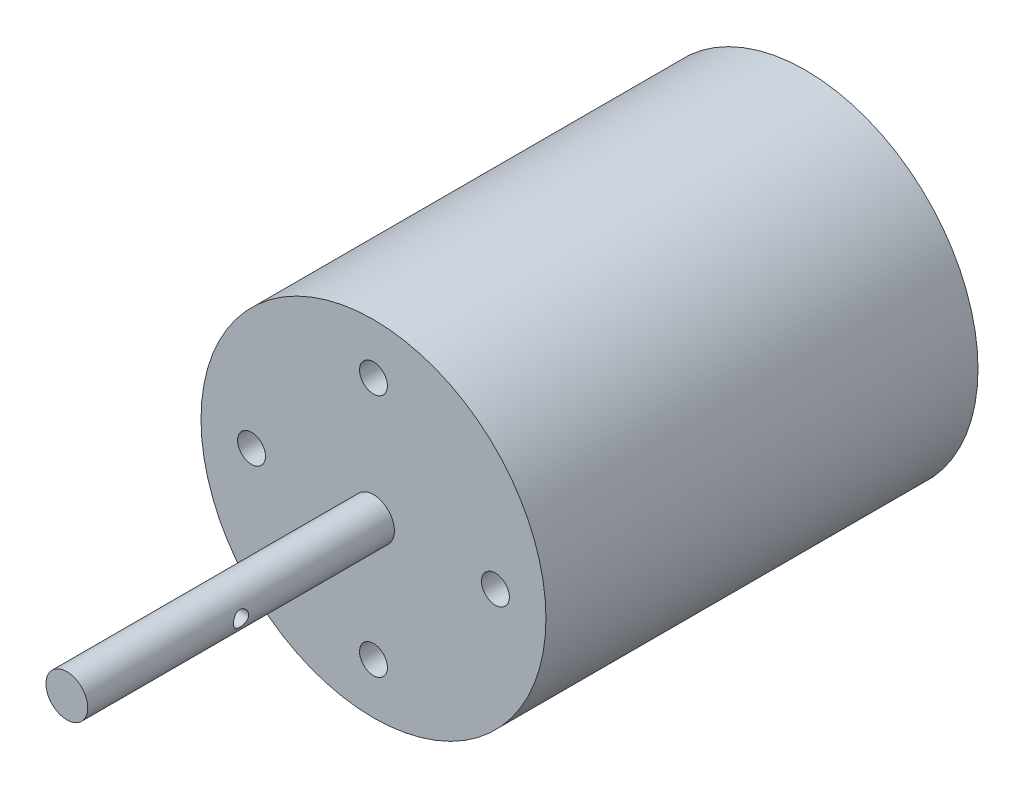
from build123d import *

# Parameters (mm, degrees)
SKETCH1_R               = 24.75
BOSS_EXTRUDE1_DEPTH     = 62
SKETCH2_R               = 3
BOSS_EXTRUDE2_DEPTH     = 44
SKETCH3_R               = 1.1
CUT_EXTRUDE1_DEPTH      = 25.75
CUT_EXTRUDE1_DEPTH_BACK = 25.75
SKETCH4_R               = 9
BOSS_EXTRUDE3_DEPTH     = 7
SKETCH5_R               = 2
CUT_EXTRUDE2_DEPTH      = 10
SKETCH6_R               = 2
CUT_EXTRUDE3_DEPTH      = 5


with BuildPart() as part:
    # Sketch1 → Boss-Extrude1 (new body)
    with BuildSketch(Plane.XY):
        Circle(SKETCH1_R)
    extrude(amount=-BOSS_EXTRUDE1_DEPTH)

    # Sketch2 → Boss-Extrude2 (add)
    with BuildSketch(Plane.XY):
        Circle(SKETCH2_R)
    extrude(amount=BOSS_EXTRUDE2_DEPTH)

    # Sketch3 → Cut-Extrude1 (cut, two sides)
    with BuildSketch(Plane(origin=(0, 0, 0), x_dir=(0, 0, -1), z_dir=(1, 0, 0))) as cut_extrude1_sk:
        with Locations((-22, 0)):
            Circle(SKETCH3_R)
    extrude(amount=CUT_EXTRUDE1_DEPTH, mode=Mode.SUBTRACT)
    extrude(cut_extrude1_sk.sketch, amount=-CUT_EXTRUDE1_DEPTH_BACK, mode=Mode.SUBTRACT)

    # Sketch4 → Boss-Extrude3 (add)
    with BuildSketch(Plane(origin=(0, 0, -62), x_dir=(-1, 0, 0), z_dir=(0, 0, -1))):
        Circle(SKETCH4_R)
    extrude(amount=BOSS_EXTRUDE3_DEPTH)

    # Sketch5 → Cut-Extrude2 (cut)
    with BuildSketch(Plane(origin=(0, 0, -62), x_dir=(-1, 0, 0), z_dir=(0, 0, -1))):
        with Locations((-17.5, 0)):
            Circle(SKETCH5_R)
        with Locations((17.5, 0)):
            Circle(SKETCH5_R)
    extrude(amount=-CUT_EXTRUDE2_DEPTH, mode=Mode.SUBTRACT)

    # Sketch6 → Cut-Extrude3 (cut)
    with BuildSketch(Plane.XY):
        with Locations((0, 17.5)):
            Circle(SKETCH6_R)
        with Locations((17.5, 0)):
            Circle(SKETCH6_R)
        with Locations((0, -17.5)):
            Circle(SKETCH6_R)
        with Locations((-17.5, 0)):
            Circle(SKETCH6_R)
    extrude(amount=-CUT_EXTRUDE3_DEPTH, mode=Mode.SUBTRACT)


solid = part.part
